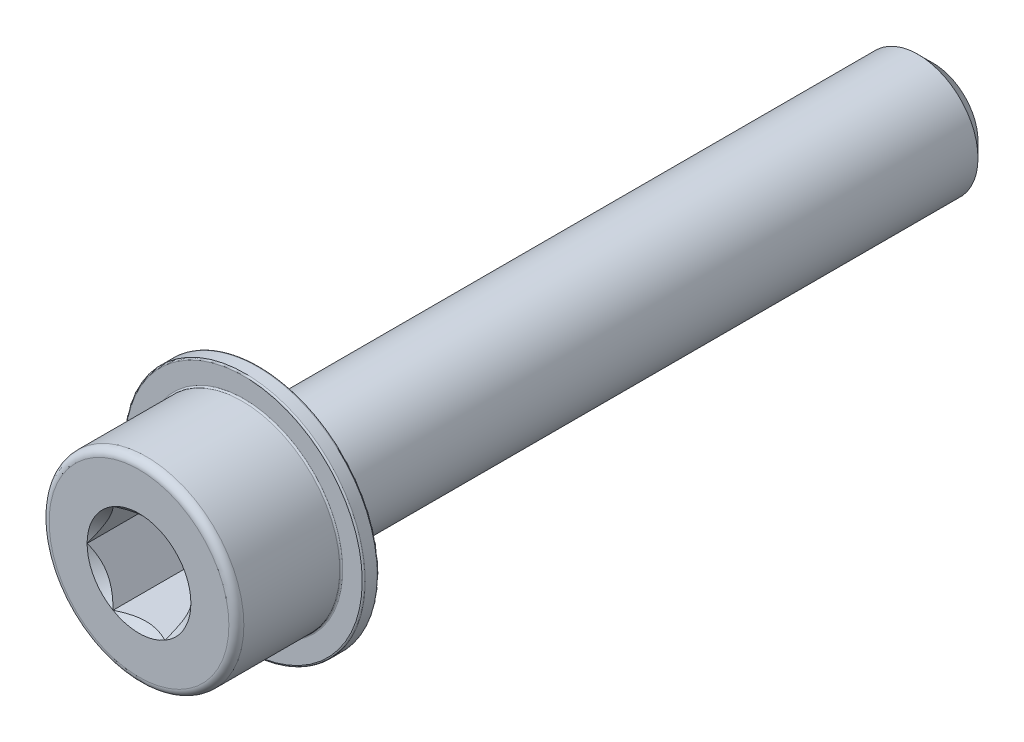
from build123d import *

# Parameters (mm, degrees)
SCHIZZO1_R                   = 4
ESTRUSIONE_ESTRUSIONE1_DEPTH = 45
SMUSSO1_SIZE                 = 1
SCHIZZO6_R                   = 6.5
ESTRUSIONE_ESTRUSIONE3_DEPTH = 8
TAGLIO_ESTRUSIONE3_DEPTH     = 6
SCHIZZO8_R                   = 3.464101615
TAGLIO_ESTRUSIONE4_DEPTH     = 1
TAGLIO_ESTRUSIONE4_TAPER     = 45
RACCORDO1_R                  = 0.5
SCHIZZO9_R                   = 8
SCHIZZO9_R_2                 = 6.5
ESTRUSIONE_ESTRUSIONE4_DEPTH = 1
RACCORDO2_R                  = 0.1


with BuildPart() as part:
    # Schizzo1 → Estrusione-Estrusione1 (new body)
    with BuildSketch(Plane.XY):
        Circle(SCHIZZO1_R)
    extrude(amount=ESTRUSIONE_ESTRUSIONE1_DEPTH)

    # Smusso1
    smusso1_edges = [part.edges().sort_by_distance(p)[0] for p in [
        (-4, 0, 0),
    ]]
    chamfer(smusso1_edges, length=SMUSSO1_SIZE)

    # Schizzo6 → Estrusione-Estrusione3 (add)
    with BuildSketch(Plane.XY.offset(45)):
        Circle(SCHIZZO6_R)
    extrude(amount=ESTRUSIONE_ESTRUSIONE3_DEPTH)

    # Schizzo7 → Taglio-Estrusione3 (cut)
    with BuildSketch(Plane.XY.offset(53)):
        Polygon((1.732050808, 3), (-1.732050808, 3), (-3.464101615, 0), (-1.732050808, -3), (1.732050808, -3), (3.464101615, 0), align=None)
    extrude(amount=-TAGLIO_ESTRUSIONE3_DEPTH, mode=Mode.SUBTRACT)

    # Schizzo8 → Taglio-Estrusione4 (cut)
    with BuildSketch(Plane.XY.offset(53)):
        Circle(SCHIZZO8_R)
    extrude(amount=-TAGLIO_ESTRUSIONE4_DEPTH, taper=TAGLIO_ESTRUSIONE4_TAPER, mode=Mode.SUBTRACT)

    # Raccordo1
    raccordo1_edges = [part.edges().sort_by_distance(p)[0] for p in [
        (-6.5, 0, 53),
    ]]
    fillet(raccordo1_edges, radius=RACCORDO1_R)

    # Schizzo9 → Estrusione-Estrusione4 (add)
    with BuildSketch(Plane(origin=(0, 0, 45), x_dir=(-1, 0, 0), z_dir=(0, 0, -1))):
        Circle(SCHIZZO9_R)
        Circle(SCHIZZO9_R_2, mode=Mode.SUBTRACT)
    extrude(amount=-ESTRUSIONE_ESTRUSIONE4_DEPTH)

    # Raccordo2
    raccordo2_edges = [part.edges().sort_by_distance(p)[0] for p in [
        (-6.5, 0, 46),
        (8, 0, 46),
        (8, 0, 45),
    ]]
    fillet(raccordo2_edges, radius=RACCORDO2_R)


solid = part.part
